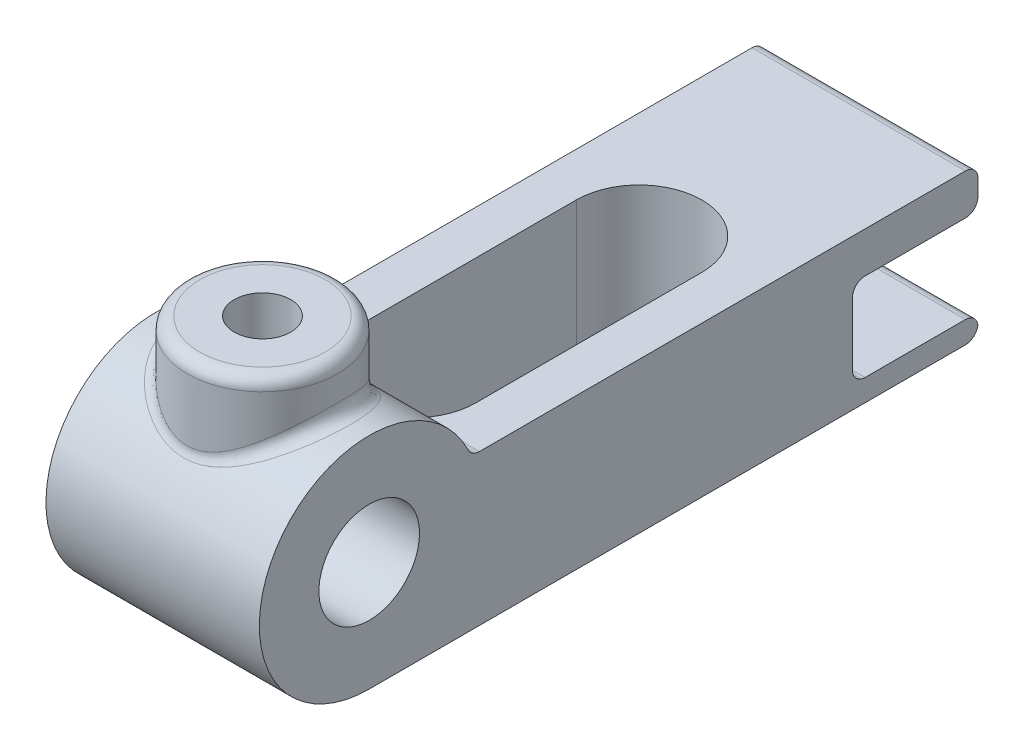
from build123d import *

# Parameters (mm, degrees)
SKETCH1_R                = 6.3627
BOSS_EXTRUDE1_DEPTH      = 13.49375
CUT_EXTRUDE1_DEPTH       = 81.455088889
CUT_EXTRUDE1_DEPTH_BACK  = 81.455088889
BOSS_EXTRUDE2_REACH      = 87.294
BOSS_EXTRUDE2_END_RADIUS = 13.890625
SKETCH3_R                = 9.525
SKETCH3_R_2              = 3.571875
CUT_EXTRUDE2_REACH       = 87.294
CUT_EXTRUDE2_END_RADIUS  = 6.3627
SKETCH3_2_R              = 3.571875
FILLET1_R                = 1.5875


with BuildPart() as part:
    # Sketch1 → Boss-Extrude1 (new, symmetric)
    with BuildSketch(Plane(origin=(0, 0, 0), x_dir=(0, 0, -1), z_dir=(1, 0, 0))):
        with BuildLine():
            ThreePointArc((76.99375, 3.571875), (76.528782015, 4.694407015), (75.40625, 5.159375))
            Line((75.40625, 5.159375), (12.896910967, 5.159375))
            ThreePointArc((12.896910967, 5.159375), (-11.502530292, 7.78724982), (0, -13.890625))
            Line((0, -13.890625), (75.40625, -13.890625))
            ThreePointArc((75.40625, -13.890625), (76.456282552, -13.49375), (76.981298827, -12.5015625))
            ThreePointArc((76.981298827, -12.5015625), (76.456282552, -11.509375), (75.40625, -11.1125))
            Line((75.40625, -11.1125), (62.70625, -11.1125))
            ThreePointArc((62.70625, -11.1125), (61.583717985, -10.647532015), (61.11875, -9.525))
            Line((61.11875, -9.525), (61.11875, -1.5875))
            ThreePointArc((61.11875, -1.5875), (61.583717985, -0.464967985), (62.70625, 0))
            Line((62.70625, 0), (75.40625, 0))
            ThreePointArc((75.40625, 0), (76.528782015, 0.464967985), (76.99375, 1.5875))
            Line((76.99375, 1.5875), (76.99375, 3.571875))
        make_face()
        Circle(SKETCH1_R, mode=Mode.SUBTRACT)
    extrude(amount=BOSS_EXTRUDE1_DEPTH, both=True)

    # Sketch2 → Cut-Extrude1 (cut, two sides: drawn at the far end of the back side and taken through both)
    with BuildSketch(Plane(origin=(0, 5.159375, 0), x_dir=(1, 0, 0), z_dir=(0, 1, 0)).offset(-CUT_EXTRUDE1_DEPTH_BACK)):
        with BuildLine():
            Line((7.9375, 47.625), (7.9375, 19.05))
            ThreePointArc((7.9375, 19.05), (0, 11.1125), (-7.9375, 19.05))
            Line((-7.9375, 19.05), (-7.9375, 47.625))
            ThreePointArc((-7.9375, 47.625), (0, 55.5625), (7.9375, 47.625))
        make_face()
    extrude(amount=CUT_EXTRUDE1_DEPTH + CUT_EXTRUDE1_DEPTH_BACK, mode=Mode.SUBTRACT)

    # Boss-Extrude2: up to this cylinder (the profile starts outside it)
    boss_extrude2_end = Plane(origin=(-9.255592, 0, 0), z_dir=(-1, 0, 0)) * Cylinder(BOSS_EXTRUDE2_END_RADIUS, 203.36925, mode=Mode.PRIVATE)
    # Sketch3 → Boss-Extrude2 (add, up to the surface)
    with BuildSketch(Plane(origin=(0, 20.240625, 0), x_dir=(1, 0, 0), z_dir=(0, 1, 0)), mode=Mode.PRIVATE) as boss_extrude2_sk1:
        Circle(SKETCH3_R)
        Circle(SKETCH3_R_2, mode=Mode.SUBTRACT)
    boss_extrude2_tool1 = extrude(boss_extrude2_sk1.sketch, amount=-BOSS_EXTRUDE2_REACH, mode=Mode.PRIVATE) - boss_extrude2_end
    add(boss_extrude2_tool1.solids().sort_by_distance((-9.255592, 20.240625, 0))[0])

    # Cut-Extrude2: up to this cylinder (the profile starts outside it)
    cut_extrude2_end = Plane(origin=(0, 0, 0), z_dir=(-1, 0, 0)) * Cylinder(CUT_EXTRUDE2_END_RADIUS, 188.3134, mode=Mode.PRIVATE)
    # Sketch3_2 → Cut-Extrude2 (cut, up to the surface)
    with BuildSketch(Plane(origin=(0, 20.240625, 0), x_dir=(1, 0, 0), z_dir=(0, 1, 0)), mode=Mode.PRIVATE) as cut_extrude2_sk1:
        Circle(SKETCH3_2_R)
    cut_extrude2_tool1 = extrude(cut_extrude2_sk1.sketch, amount=-CUT_EXTRUDE2_REACH, mode=Mode.PRIVATE) - cut_extrude2_end
    add(cut_extrude2_tool1.solids().sort_by_distance((0, 20.240625, 0))[0], mode=Mode.SUBTRACT)

    # Fillet1
    fillet1_edges = [part.edges().sort_by_distance(p)[0] for p in [
        (-9.525, 20.240625, 0),
        (-9.254034828, 5.159375, -12.896910967),
        (9.254034828, 5.159375, -12.896910967),
        (-9.525, 13.890625004, -1e-09),
    ]]
    fillet(fillet1_edges, radius=FILLET1_R)


solid = part.part
